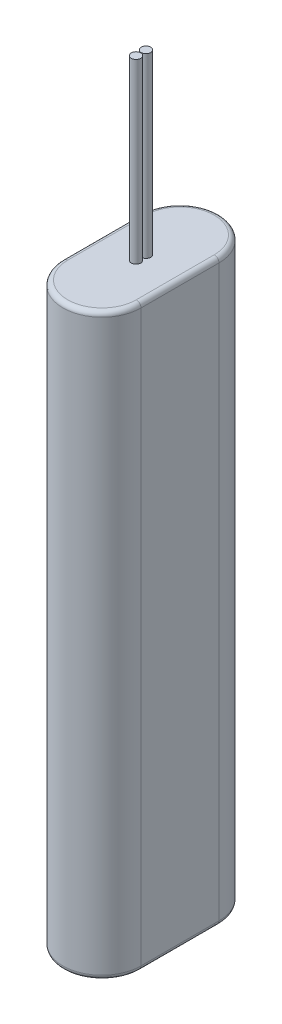
from build123d import *

# Parameters (mm, degrees)
EXTRUSION1_DEPTH = 245
CONG_1_R         = 2
ESQUISSE2_R      = 2
EXTRUSION2_DEPTH = 75


with BuildPart() as part:
    # Esquisse1 → Extrusion1 (new body)
    with BuildSketch(Plane(origin=(0, 0, 0), x_dir=(1, 0, 0), z_dir=(0, 1, 0))):
        with BuildLine():
            Line((0, 0), (0, 33))
            ThreePointArc((0, 33), (16.5, 49.5), (33, 33))
            Line((33, 33), (33, 0))
            ThreePointArc((33, 0), (16.5, -16.5), (0, 0))
        make_face()
    extrude(amount=EXTRUSION1_DEPTH)

    # Congé1
    cong_1_edges = [part.edges().sort_by_distance(p)[0] for p in [
        (16.5, 245, -49.5),
        (0, 245, -16.5),
        (16.5, 245, 16.5),
        (0, 0, -16.5),
        (16.5, 0, -49.5),
        (33, 0, -16.5),
        (16.5, 0, 16.5),
        (33, 245, -16.5),
    ]]
    fillet(cong_1_edges, radius=CONG_1_R)

    # Esquisse2 → Extrusion2 (add)
    with BuildSketch(Plane(origin=(0, 245, 0), x_dir=(1, 0, 0), z_dir=(0, 1, 0))):
        with Locations((16.5, 18.6)):
            Circle(ESQUISSE2_R)
        with Locations((16.5, 14.4)):
            Circle(ESQUISSE2_R)
    extrude(amount=EXTRUSION2_DEPTH)


solid = part.part
